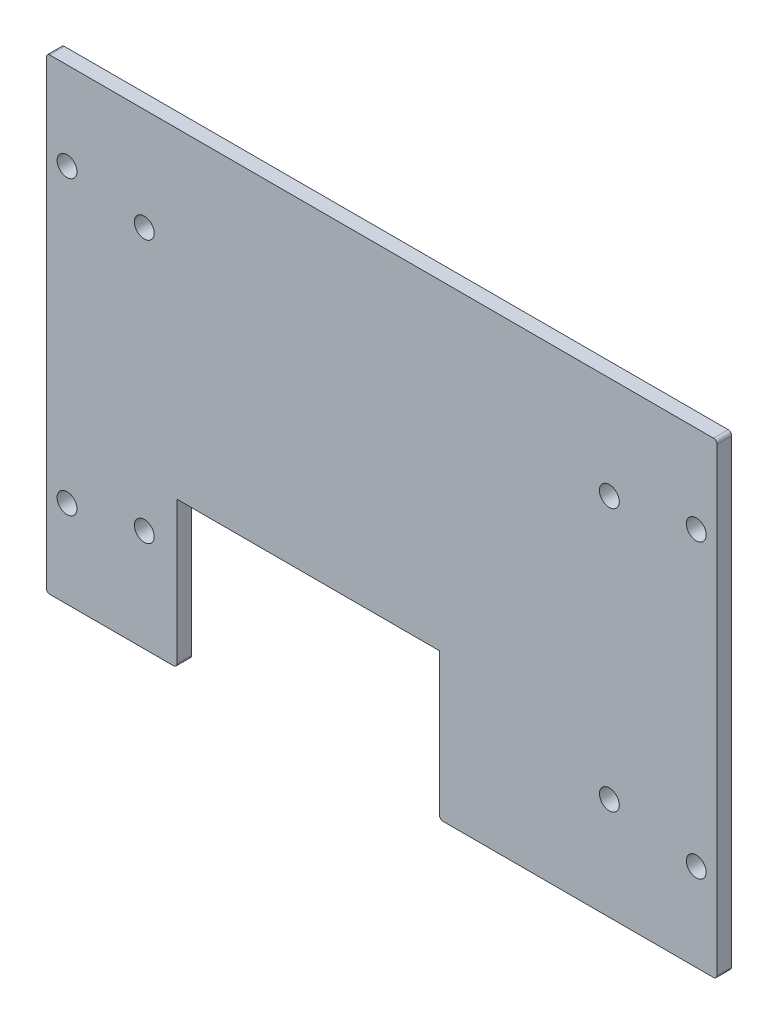
from build123d import *

# Parameters (mm, degrees)
SKETCH1_W           = 145.885353282
SKETCH1_H           = 101.6
BOSS_EXTRUDE1_DEPTH = 3.2004
SKETCH4_W           = 57.100000132
SKETCH4_H           = 31.75
CUT_EXTRUDE1_DEPTH  = 3.2004
SKETCH5_R           = 2.159
CUT_EXTRUDE2_DEPTH  = 3.2004
FILLET1_R           = 0.762


with BuildPart() as part:
    # Sketch1 → Boss-Extrude1 (new body)
    with BuildSketch(Plane.XY):
        with Locations((72.942676641, 50.8)):
            Rectangle(SKETCH1_W, SKETCH1_H)
    extrude(amount=BOSS_EXTRUDE1_DEPTH)

    # Sketch4 → Cut-Extrude1 (cut)
    with BuildSketch(Plane.XY.offset(3.2004)):
        with Locations((56.982760066, 15.875)):
            Rectangle(SKETCH4_W, SKETCH4_H)
    extrude(amount=-CUT_EXTRUDE1_DEPTH, mode=Mode.SUBTRACT)

    # Sketch5 → Cut-Extrude2 (cut)
    with BuildSketch(Plane.XY.offset(3.2004)):
        with Locations((141.376853282, 82.55)):
            Circle(SKETCH5_R)
        with Locations((141.376853282, 19.05)):
            Circle(SKETCH5_R)
        with Locations((4.5085, 19.05)):
            Circle(SKETCH5_R)
        with Locations((4.5085, 82.55)):
            Circle(SKETCH5_R)
        with Locations((21.31994339, 79.375)):
            Circle(SKETCH5_R)
        with Locations((21.31994339, 22.225)):
            Circle(SKETCH5_R)
        with Locations((122.472903282, 79.375)):
            Circle(SKETCH5_R)
        with Locations((122.472903282, 22.225)):
            Circle(SKETCH5_R)
    extrude(amount=-CUT_EXTRUDE2_DEPTH, mode=Mode.SUBTRACT)

    # Fillet1
    fillet1_edges = [part.edges().sort_by_distance(p)[0] for p in [
        (28.43276, 0, 1.6002),
        (85.532760132, 0, 1.6002),
        (0, 101.6, 1.6002),
        (145.885353282, 101.6, 1.6002),
        (145.885353282, 0, 1.6002),
        (0, 0, 1.6002),
    ]]
    fillet(fillet1_edges, radius=FILLET1_R)


solid = part.part
